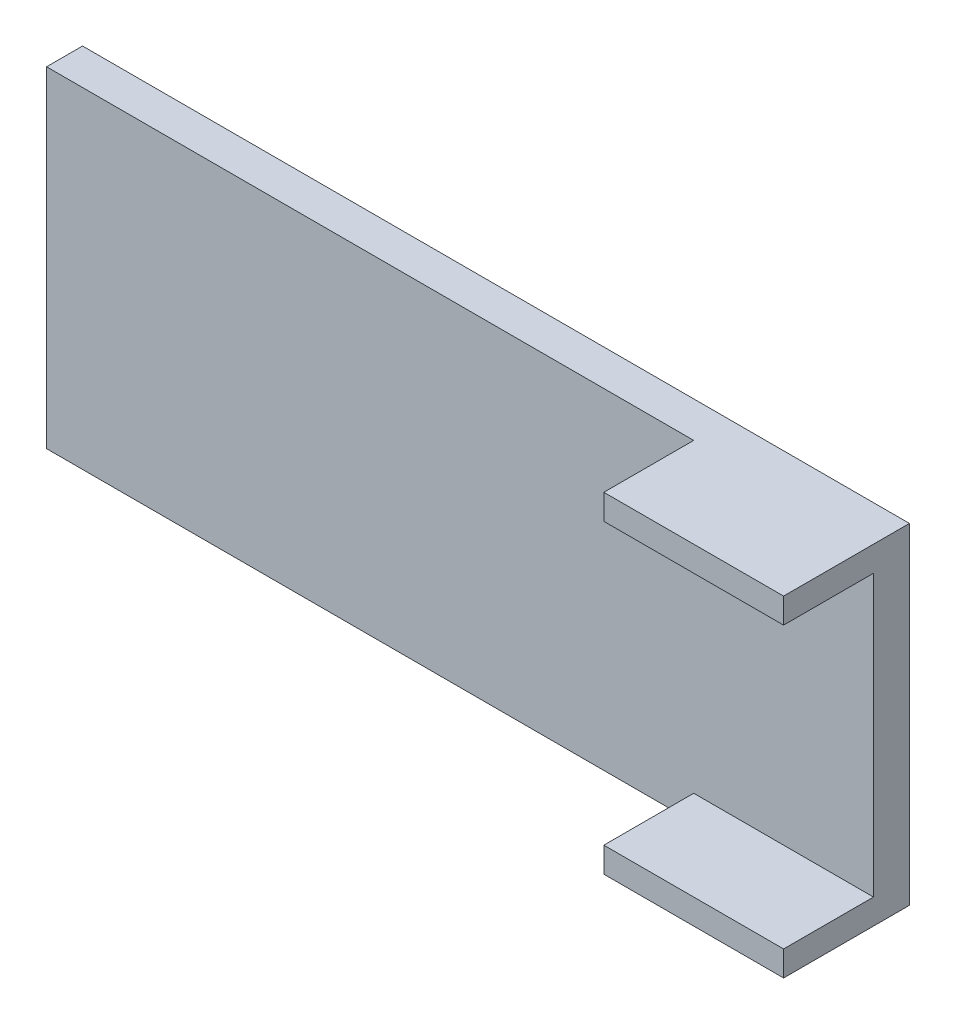
from build123d import *

# Parameters (mm, degrees)
SKETCH2_W           = 58.42
SKETCH2_H           = 23.368
BOSS_EXTRUDE1_DEPTH = 2.54
SKETCH3_W           = 12.7
SKETCH3_H           = 1.778
BOSS_EXTRUDE2_DEPTH = 6.35


with BuildPart() as part:
    # Sketch2 → Boss-Extrude1 (new body)
    with BuildSketch(Plane.XY):
        Rectangle(SKETCH2_W, SKETCH2_H)
    extrude(amount=BOSS_EXTRUDE1_DEPTH)

    # Sketch3 → Boss-Extrude2 (add)
    with BuildSketch(Plane.XY.offset(2.54)):
        with Locations((22.86, 10.795)):
            Rectangle(SKETCH3_W, SKETCH3_H)
        with Locations((22.86, -10.795)):
            Rectangle(SKETCH3_W, SKETCH3_H)
    extrude(amount=BOSS_EXTRUDE2_DEPTH)


solid = part.part
